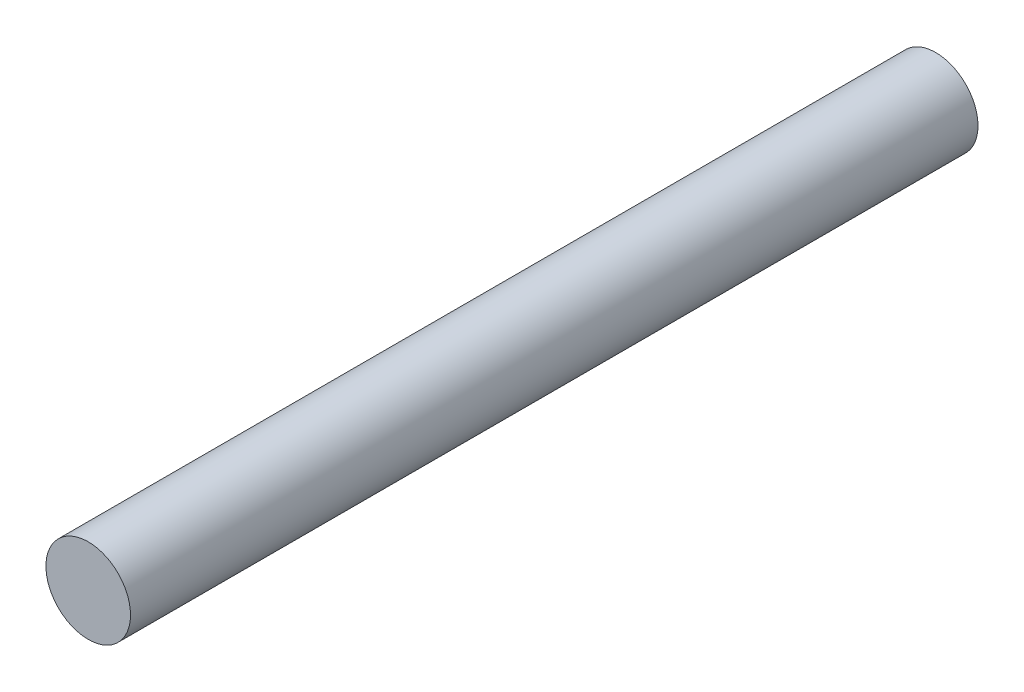
from build123d import *

# Parameters (mm, degrees)
SKETCH1_R      = 1.27
EXTRUDE1_DEPTH = 25.44572


with BuildPart() as part:
    # Sketch1 → Extrude1 (new body)
    with BuildSketch(Plane.XY):
        Circle(SKETCH1_R)
    extrude(amount=EXTRUDE1_DEPTH)


solid = part.part
